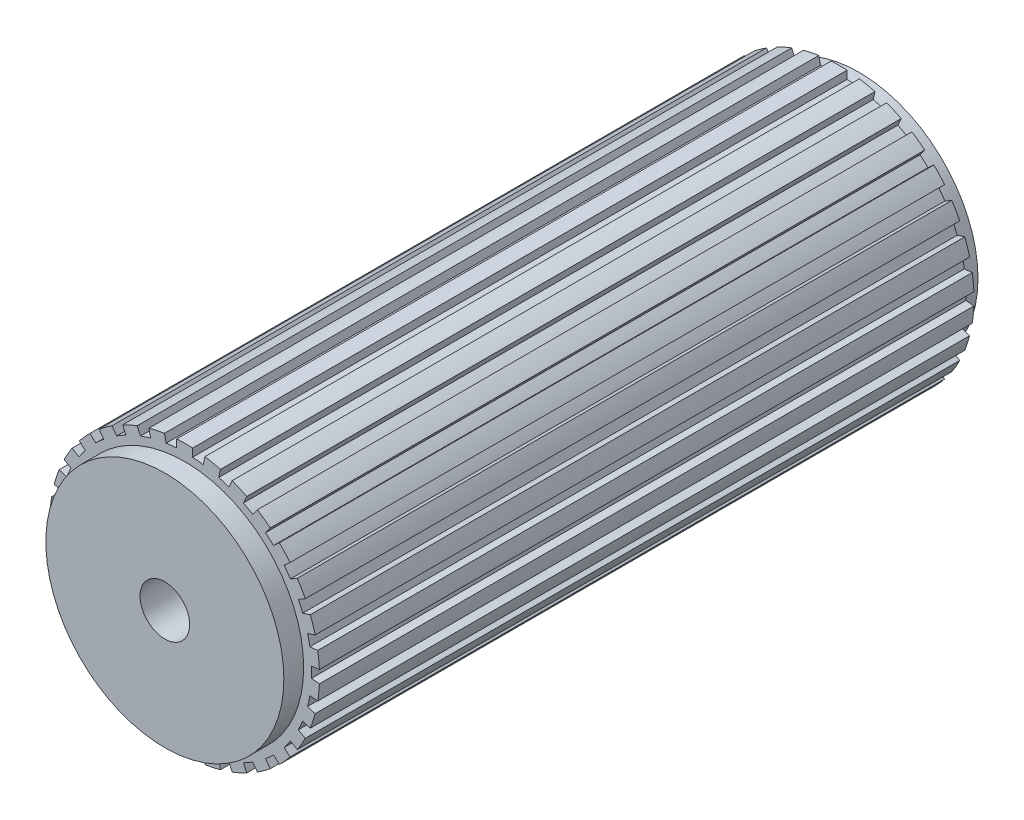
from build123d import *

# Parameters (mm, degrees)
SKETCH1_R           = 60
SKETCH1_R_2         = 12.5
BOSS_EXTRUDE1_DEPTH = 350
SKETCH2_R           = 60
BOSS_EXTRUDE2_DEPTH = 330


with BuildPart() as part:
    # Sketch1 → Boss-Extrude1 (new body)
    with BuildSketch(Plane.XY):
        Circle(SKETCH1_R)
        Circle(SKETCH1_R_2, mode=Mode.SUBTRACT)
    extrude(amount=BOSS_EXTRUDE1_DEPTH)

    # Sketch2 → Boss-Extrude2 (add)
    with BuildSketch(Plane.XY.offset(340)):
        with BuildLine():
            Line((9.367743419, 63.310705124), (10.200923178, 67.230507705))
            ThreePointArc((10.200923178, 67.230507705), (14.137994976, 66.51403685), (18.026103984, 65.567214179))
            Line((18.026103984, 65.567214179), (17.192924224, 61.647411597))
            ThreePointArc((17.192924224, 61.647411597), (19.77708764, 60.867617043), (22.326071498, 59.979550944))
            Line((22.326071498, 59.979550944), (23.956017063, 63.640468622))
            ThreePointArc((23.956017063, 63.640468622), (27.658091729, 62.12109112), (31.264380724, 60.386575478))
            Line((31.264380724, 60.386575478), (29.634435159, 56.725657799))
            ThreePointArc((29.634435159, 56.725657799), (32, 55.425625842), (34.308643121, 54.027002575))
            Line((34.308643121, 54.027002575), (36.664118049, 57.26903568))
            ThreePointArc((36.664118049, 57.26903568), (39.969397156, 55.013155617), (43.136254004, 52.566753661))
            Line((43.136254004, 52.566753661), (40.780779076, 49.324720556))
            ThreePointArc((40.780779076, 49.324720556), (42.824358807, 47.561268831), (44.791762408, 45.713214942))
            Line((44.791762408, 45.713214942), (47.769821142, 48.39467107))
            ThreePointArc((47.769821142, 48.39467107), (50.533848132, 45.500881232), (53.122865993, 42.449512467))
            Line((53.122865993, 42.449512467), (50.144807259, 39.768056338))
            ThreePointArc((50.144807259, 39.768056338), (51.77708764, 37.618256147), (53.317266744, 35.40154046))
            Line((53.317266744, 35.40154046), (56.787753827, 37.405227112))
            ThreePointArc((56.787753827, 37.405227112), (58.889727457, 34), (60.787753827, 30.477023882))
            Line((60.787753827, 30.477023882), (57.317266744, 28.47333723))
            ThreePointArc((57.317266744, 28.47333723), (58.466909289, 26.031145157), (59.512550678, 23.542648785))
            Line((59.512550678, 23.542648785), (63.323789171, 24.780995239))
            ThreePointArc((63.323789171, 24.780995239), (64.671843108, 21.013155617), (65.795925126, 17.172543108))
            Line((65.795925126, 17.172543108), (61.984686633, 15.934196655))
            ThreePointArc((61.984686633, 15.934196655), (62.601446447, 13.306348212), (63.106850574, 10.654830388))
            Line((63.106850574, 10.654830388), (67.092271067, 11.073714961))
            ThreePointArc((67.092271067, 11.073714961), (67.627488885, 7.107935502), (67.928498773, 3.117539798))
            Line((67.928498773, 3.117539798), (63.94307828, 2.698655225))
            ThreePointArc((63.94307828, 2.698655225), (64, 0), (63.94307828, -2.698655225))
            Line((63.94307828, -2.698655225), (67.928498773, -3.117539798))
            ThreePointArc((67.928498773, -3.117539798), (67.627488885, -7.107935502), (67.092271067, -11.073714961))
            Line((67.092271067, -11.073714961), (63.106850574, -10.654830388))
            ThreePointArc((63.106850574, -10.654830388), (62.601446447, -13.306348212), (61.984686633, -15.934196655))
            Line((61.984686633, -15.934196655), (65.795925126, -17.172543108))
            ThreePointArc((65.795925126, -17.172543108), (64.671843108, -21.013155617), (63.323789171, -24.780995239))
            Line((63.323789171, -24.780995239), (59.512550678, -23.542648785))
            ThreePointArc((59.512550678, -23.542648785), (58.466909289, -26.031145157), (57.317266744, -28.47333723))
            Line((57.317266744, -28.47333723), (60.787753827, -30.477023882))
            ThreePointArc((60.787753827, -30.477023882), (58.889727457, -34), (56.787753827, -37.405227112))
            Line((56.787753827, -37.405227112), (53.317266744, -35.40154046))
            ThreePointArc((53.317266744, -35.40154046), (51.77708764, -37.618256147), (50.144807259, -39.768056338))
            Line((50.144807259, -39.768056338), (53.122865993, -42.449512467))
            ThreePointArc((53.122865993, -42.449512467), (50.533848132, -45.500881232), (47.769821142, -48.39467107))
            Line((47.769821142, -48.39467107), (44.791762408, -45.713214942))
            ThreePointArc((44.791762408, -45.713214942), (42.824358807, -47.561268831), (40.780779076, -49.324720556))
            Line((40.780779076, -49.324720556), (43.136254004, -52.566753661))
            ThreePointArc((43.136254004, -52.566753661), (39.969397156, -55.013155617), (36.664118049, -57.26903568))
            Line((36.664118049, -57.26903568), (34.308643121, -54.027002575))
            ThreePointArc((34.308643121, -54.027002575), (32, -55.425625842), (29.634435159, -56.725657799))
            Line((29.634435159, -56.725657799), (31.264380724, -60.386575478))
            ThreePointArc((31.264380724, -60.386575478), (27.658091729, -62.12109112), (23.956017063, -63.640468622))
            Line((23.956017063, -63.640468622), (22.326071498, -59.979550944))
            ThreePointArc((22.326071498, -59.979550944), (19.77708764, -60.867617043), (17.192924224, -61.647411597))
            Line((17.192924224, -61.647411597), (18.026103984, -65.567214179))
            ThreePointArc((18.026103984, -65.567214179), (14.137994976, -66.51403685), (10.200923178, -67.230507705))
            Line((10.200923178, -67.230507705), (9.367743419, -63.310705124))
            ThreePointArc((9.367743419, -63.310705124), (6.689821649, -63.649401304), (4, -63.874877691))
            Line((4, -63.874877691), (4, -67.882250994))
            ThreePointArc((4, -67.882250994), (0, -68), (-4, -67.882250994))
            Line((-4, -67.882250994), (-4, -63.874877691))
            ThreePointArc((-4, -63.874877691), (-6.689821649, -63.649401304), (-9.367743419, -63.310705124))
            Line((-9.367743419, -63.310705124), (-10.200923178, -67.230507705))
            ThreePointArc((-10.200923178, -67.230507705), (-14.137994976, -66.51403685), (-18.026103984, -65.567214179))
            Line((-18.026103984, -65.567214179), (-17.192924224, -61.647411597))
            ThreePointArc((-17.192924224, -61.647411597), (-19.77708764, -60.867617043), (-22.326071498, -59.979550944))
            Line((-22.326071498, -59.979550944), (-23.956017063, -63.640468622))
            ThreePointArc((-23.956017063, -63.640468622), (-27.658091729, -62.12109112), (-31.264380724, -60.386575478))
            Line((-31.264380724, -60.386575478), (-29.634435159, -56.725657799))
            ThreePointArc((-29.634435159, -56.725657799), (-32, -55.425625842), (-34.308643121, -54.027002575))
            Line((-34.308643121, -54.027002575), (-36.664118049, -57.26903568))
            ThreePointArc((-36.664118049, -57.26903568), (-39.969397156, -55.013155617), (-43.136254004, -52.566753661))
            Line((-43.136254004, -52.566753661), (-40.780779076, -49.324720556))
            ThreePointArc((-40.780779076, -49.324720556), (-42.824358807, -47.561268831), (-44.791762408, -45.713214942))
            Line((-44.791762408, -45.713214942), (-47.769821142, -48.39467107))
            ThreePointArc((-47.769821142, -48.39467107), (-50.533848132, -45.500881232), (-53.122865993, -42.449512467))
            Line((-53.122865993, -42.449512467), (-50.144807259, -39.768056338))
            ThreePointArc((-50.144807259, -39.768056338), (-51.77708764, -37.618256147), (-53.317266744, -35.40154046))
            Line((-53.317266744, -35.40154046), (-56.787753827, -37.405227112))
            ThreePointArc((-56.787753827, -37.405227112), (-58.889727457, -34), (-60.787753827, -30.477023882))
            Line((-60.787753827, -30.477023882), (-57.317266744, -28.47333723))
            ThreePointArc((-57.317266744, -28.47333723), (-58.466909289, -26.031145157), (-59.512550678, -23.542648785))
            Line((-59.512550678, -23.542648785), (-63.323789171, -24.780995239))
            ThreePointArc((-63.323789171, -24.780995239), (-64.671843108, -21.013155617), (-65.795925126, -17.172543108))
            Line((-65.795925126, -17.172543108), (-61.984686633, -15.934196655))
            ThreePointArc((-61.984686633, -15.934196655), (-62.601446447, -13.306348212), (-63.106850574, -10.654830388))
            Line((-63.106850574, -10.654830388), (-67.092271067, -11.073714961))
            ThreePointArc((-67.092271067, -11.073714961), (-67.627488885, -7.107935502), (-67.928498773, -3.117539798))
            Line((-67.928498773, -3.117539798), (-63.94307828, -2.698655225))
            ThreePointArc((-63.94307828, -2.698655225), (-64, 0), (-63.94307828, 2.698655225))
            Line((-63.94307828, 2.698655225), (-67.928498773, 3.117539798))
            ThreePointArc((-67.928498773, 3.117539798), (-67.627488885, 7.107935502), (-67.092271067, 11.073714961))
            Line((-67.092271067, 11.073714961), (-63.106850574, 10.654830388))
            ThreePointArc((-63.106850574, 10.654830388), (-62.601446447, 13.306348212), (-61.984686633, 15.934196655))
            Line((-61.984686633, 15.934196655), (-65.795925126, 17.172543108))
            ThreePointArc((-65.795925126, 17.172543108), (-64.671843108, 21.013155617), (-63.323789171, 24.780995239))
            Line((-63.323789171, 24.780995239), (-59.512550678, 23.542648785))
            ThreePointArc((-59.512550678, 23.542648785), (-58.466909289, 26.031145157), (-57.317266744, 28.47333723))
            Line((-57.317266744, 28.47333723), (-60.787753827, 30.477023882))
            ThreePointArc((-60.787753827, 30.477023882), (-58.889727457, 34), (-56.787753827, 37.405227112))
            Line((-56.787753827, 37.405227112), (-53.317266744, 35.40154046))
            ThreePointArc((-53.317266744, 35.40154046), (-51.77708764, 37.618256147), (-50.144807259, 39.768056338))
            Line((-50.144807259, 39.768056338), (-53.122865993, 42.449512467))
            ThreePointArc((-53.122865993, 42.449512467), (-50.533848132, 45.500881232), (-47.769821142, 48.39467107))
            Line((-47.769821142, 48.39467107), (-44.791762408, 45.713214942))
            ThreePointArc((-44.791762408, 45.713214942), (-42.824358807, 47.561268831), (-40.780779076, 49.324720556))
            Line((-40.780779076, 49.324720556), (-43.136254004, 52.566753661))
            ThreePointArc((-43.136254004, 52.566753661), (-39.969397156, 55.013155617), (-36.664118049, 57.26903568))
            Line((-36.664118049, 57.26903568), (-34.308643121, 54.027002575))
            ThreePointArc((-34.308643121, 54.027002575), (-32, 55.425625842), (-29.634435159, 56.725657799))
            Line((-29.634435159, 56.725657799), (-31.264380724, 60.386575478))
            ThreePointArc((-31.264380724, 60.386575478), (-27.658091729, 62.12109112), (-23.956017063, 63.640468622))
            Line((-23.956017063, 63.640468622), (-22.326071498, 59.979550944))
            ThreePointArc((-22.326071498, 59.979550944), (-19.77708764, 60.867617043), (-17.192924224, 61.647411597))
            Line((-17.192924224, 61.647411597), (-18.026103984, 65.567214179))
            ThreePointArc((-18.026103984, 65.567214179), (-14.137994976, 66.51403685), (-10.200923178, 67.230507705))
            Line((-10.200923178, 67.230507705), (-9.367743419, 63.310705124))
            ThreePointArc((-9.367743419, 63.310705124), (-6.689821649, 63.649401304), (-4, 63.874877691))
            Line((-4, 63.874877691), (-4, 67.882250994))
            ThreePointArc((-4, 67.882250994), (0, 68), (4, 67.882250994))
            Line((4, 67.882250994), (4, 63.874877691))
            ThreePointArc((4, 63.874877691), (6.689821649, 63.649401304), (9.367743419, 63.310705124))
        make_face()
        Circle(SKETCH2_R, mode=Mode.SUBTRACT)
    extrude(amount=-BOSS_EXTRUDE2_DEPTH)


solid = part.part
